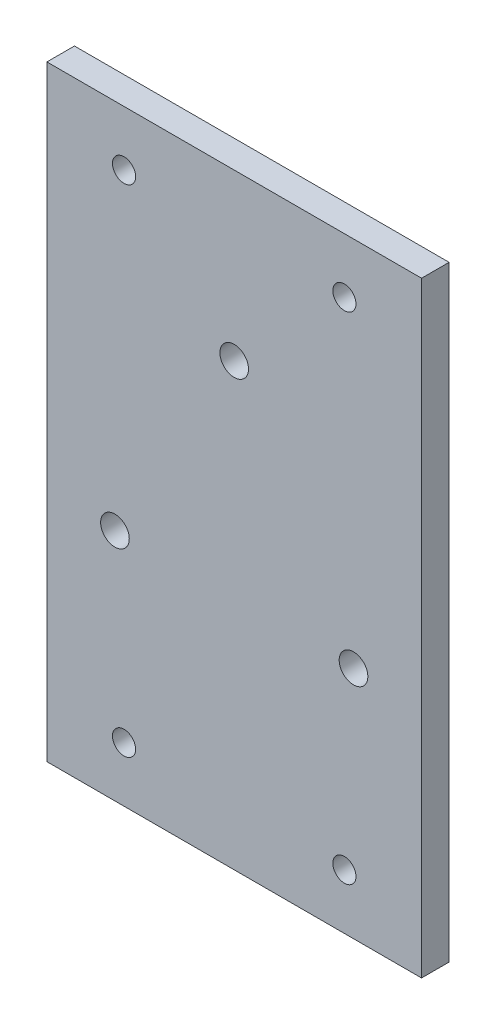
from build123d import *

# Parameters (mm, degrees)
SKETCH1_W           = 68
SKETCH1_H           = 110
SKETCH1_R           = 2.1
SKETCH1_R_2         = 2.6
BOSS_EXTRUDE1_DEPTH = 5


with BuildPart() as part:
    # Sketch1 → Boss-Extrude1 (new body)
    with BuildSketch(Plane.XY):
        Rectangle(SKETCH1_W, SKETCH1_H)
        with Locations((20, 45)):
            Circle(SKETCH1_R, mode=Mode.SUBTRACT)
        with Locations((-20, 45)):
            Circle(SKETCH1_R, mode=Mode.SUBTRACT)
        with Locations((20, -45)):
            Circle(SKETCH1_R, mode=Mode.SUBTRACT)
        with Locations((-20, -45)):
            Circle(SKETCH1_R, mode=Mode.SUBTRACT)
        with Locations((21.650635095, -12.5)):
            Circle(SKETCH1_R_2, mode=Mode.SUBTRACT)
        with Locations((0, 25)):
            Circle(SKETCH1_R_2, mode=Mode.SUBTRACT)
        with Locations((-21.650635095, -12.5)):
            Circle(SKETCH1_R_2, mode=Mode.SUBTRACT)
    extrude(amount=BOSS_EXTRUDE1_DEPTH)


solid = part.part
